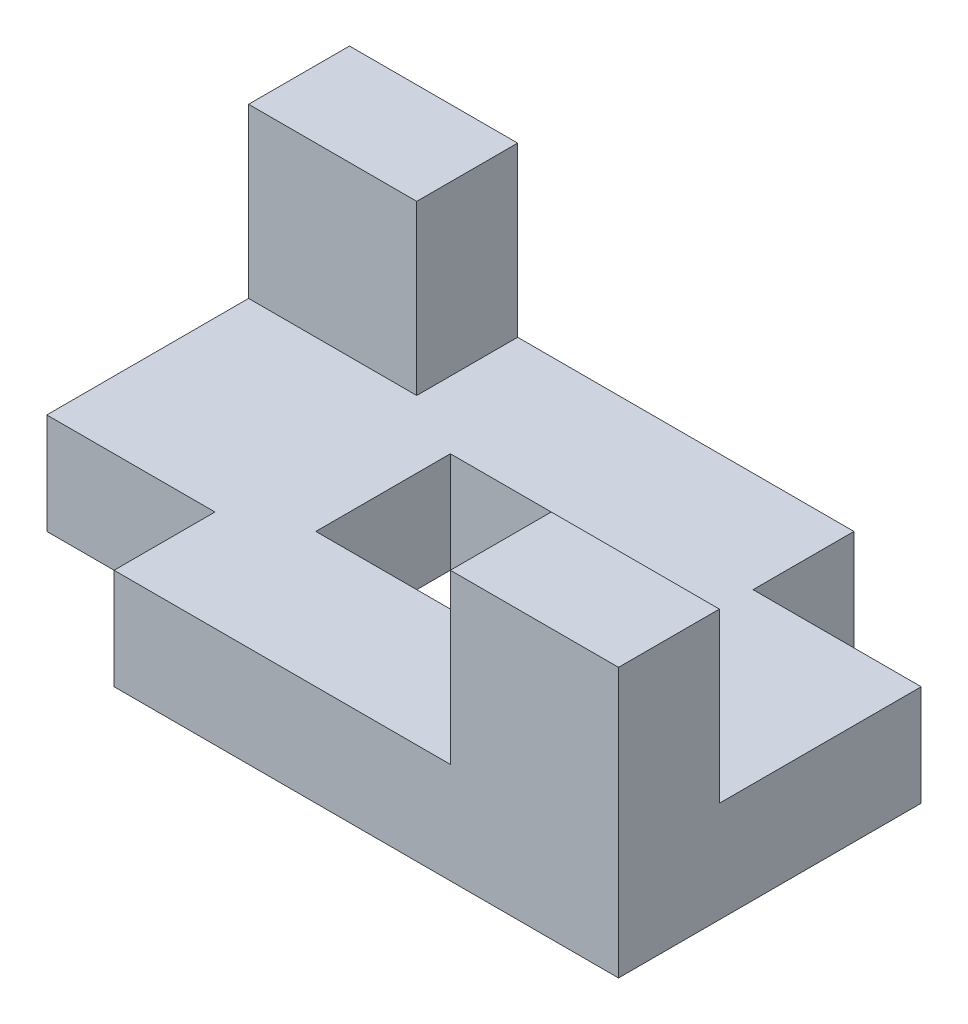
from build123d import *

# Parameters (mm, degrees)
SKETCH1_W           = 100
SKETCH1_H           = 60
BOSS_EXTRUDE1_DEPTH = 15
SKETCH2_W           = 25
SKETCH2_H           = 15
BOSS_EXTRUDE2_DEPTH = 25
SKETCH4_W           = 25
SKETCH4_H           = 15
BOSS_EXTRUDE3_DEPTH = 25
SKETCH5_W           = 25
SKETCH5_H           = 15
CUT_EXTRUDE1_DEPTH  = 25
SKETCH6_W           = 25
SKETCH6_H           = 15
CUT_EXTRUDE2_DEPTH  = 25
SKETCH7_W           = 30
SKETCH7_H           = 20
CUT_EXTRUDE3_DEPTH  = 25


with BuildPart() as part:
    # Sketch1 → Boss-Extrude1 (new body)
    with BuildSketch(Plane(origin=(0, 0, 0), x_dir=(1, 0, 0), z_dir=(0, 1, 0))):
        Rectangle(SKETCH1_W, SKETCH1_H)
    extrude(amount=BOSS_EXTRUDE1_DEPTH)

    # Sketch2 → Boss-Extrude2 (add)
    with BuildSketch(Plane(origin=(0, 15, 0), x_dir=(1, 0, 0), z_dir=(0, 1, 0))):
        with Locations((-37.5, 22.5)):
            Rectangle(SKETCH2_W, SKETCH2_H)
    extrude(amount=BOSS_EXTRUDE2_DEPTH)

    # Sketch4 → Boss-Extrude3 (add)
    with BuildSketch(Plane(origin=(0, 15, 0), x_dir=(1, 0, 0), z_dir=(0, 1, 0))):
        with Locations((37.5, -22.5)):
            Rectangle(SKETCH4_W, SKETCH4_H)
    extrude(amount=BOSS_EXTRUDE3_DEPTH)

    # Sketch5 → Cut-Extrude1 (cut)
    with BuildSketch(Plane(origin=(0, 15, 0), x_dir=(1, 0, 0), z_dir=(0, 1, 0))):
        with Locations((-37.5, -22.5)):
            Rectangle(SKETCH5_W, SKETCH5_H)
    extrude(amount=-CUT_EXTRUDE1_DEPTH, mode=Mode.SUBTRACT)

    # Sketch6 → Cut-Extrude2 (cut)
    with BuildSketch(Plane(origin=(0, 15, 0), x_dir=(1, 0, 0), z_dir=(0, 1, 0))):
        with Locations((37.5, 22.5)):
            Rectangle(SKETCH6_W, SKETCH6_H)
    extrude(amount=-CUT_EXTRUDE2_DEPTH, mode=Mode.SUBTRACT)

    # Sketch7 → Cut-Extrude3 (cut)
    with BuildSketch(Plane(origin=(0, 15, 0), x_dir=(1, 0, 0), z_dir=(0, 1, 0))):
        Rectangle(SKETCH7_W, SKETCH7_H)
    extrude(amount=-CUT_EXTRUDE3_DEPTH, mode=Mode.SUBTRACT)


solid = part.part
